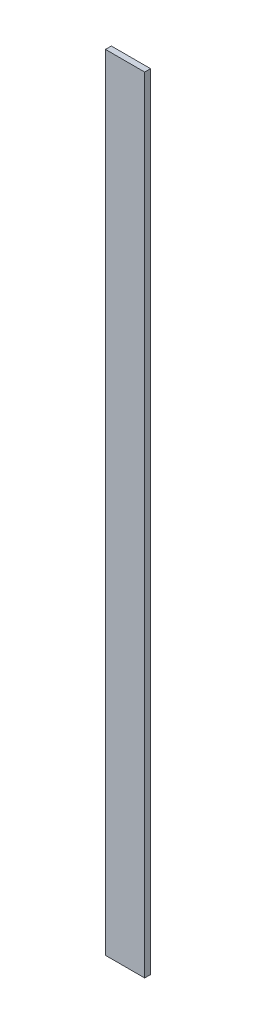
from build123d import *

# Parameters (mm, degrees)
CROQUIS1_W              = 20
CROQUIS1_H              = 400
SALIENTE_EXTRUIR1_DEPTH = 3


with BuildPart() as part:
    # Croquis1 → Saliente-Extruir1 (new body)
    with BuildSketch(Plane.XY):
        with Locations((10, 200)):
            Rectangle(CROQUIS1_W, CROQUIS1_H)
    extrude(amount=SALIENTE_EXTRUIR1_DEPTH)


solid = part.part
